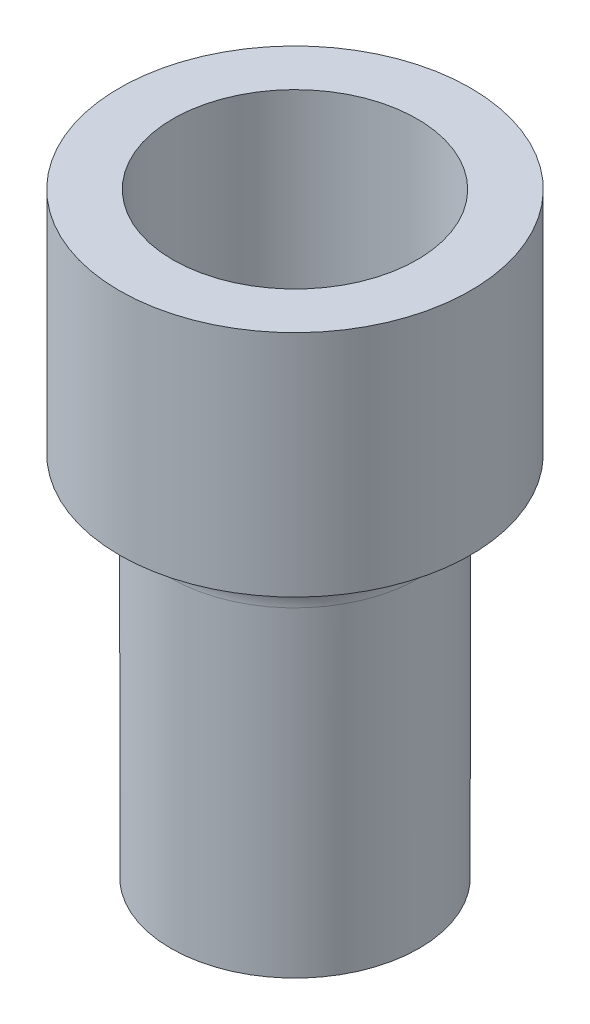
from build123d import *

# Parameters (mm, degrees)
SKETCH1_R           = 5.842
SKETCH1_R_2         = 4.064
BOSS_EXTRUDE1_DEPTH = 7.62
SKETCH3_R           = 4.1275
BOSS_EXTRUDE2_DEPTH = 12.192
FILLET2_R           = 1.524


with BuildPart() as part:
    # Sketch1 → Boss-Extrude1 (new body)
    with BuildSketch(Plane(origin=(0, 0, 0), x_dir=(1, 0, 0), z_dir=(0, 1, 0))):
        with Locations(Location((0, 0, 0), (0, 0, 270))):  # turned: the seam where the file's is
            Circle(SKETCH1_R)
        with Locations(Location((0, 0, 0), (0, 0, 270))):  # turned: the seam where the file's is
            Circle(SKETCH1_R_2, mode=Mode.SUBTRACT)
    extrude(amount=BOSS_EXTRUDE1_DEPTH)

    # Sketch3 → Boss-Extrude2 (add)
    with BuildSketch(Plane.XZ):
        with Locations(Location((0, 0, 0), (0, 0, 90))):  # turned: the seam where the file's is
            Circle(SKETCH3_R)
    extrude(amount=BOSS_EXTRUDE2_DEPTH)

    # Fillet2
    fillet2_edges = [part.edges().sort_by_distance(p)[0] for p in [
        (0, 0, -4.1275),
    ]]
    fillet(fillet2_edges, radius=FILLET2_R)


solid = part.part
